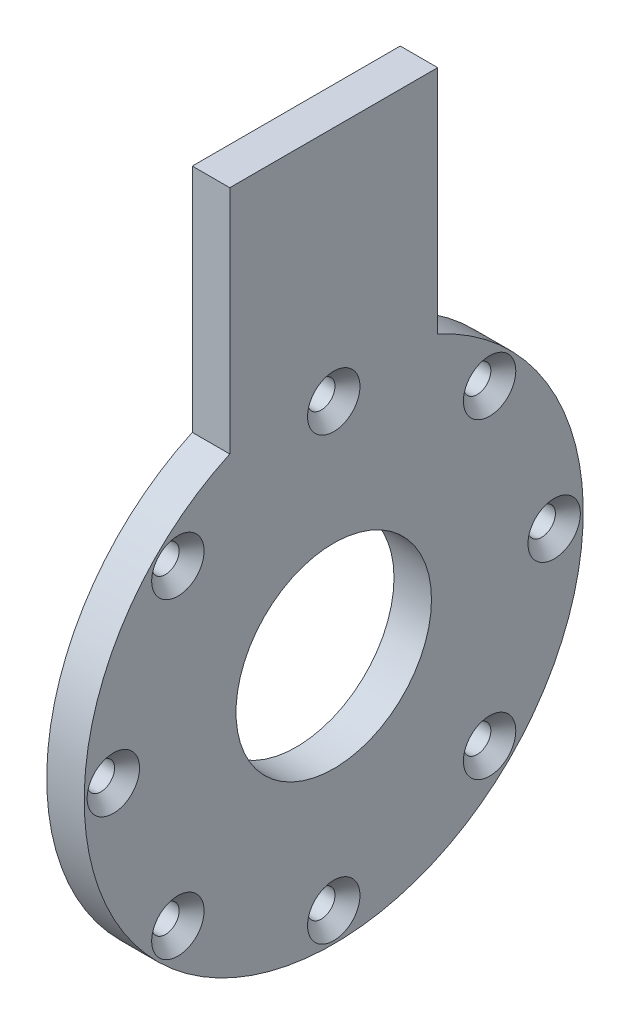
from build123d import *

# Parameters (mm, degrees)
SKETCH1_R                                           = 23.5
BOSS_EXTRUDE1_DEPTH                                 = 9
BOSS_EXTRUDE1_DEPTH_BACK                            = 0.01
CSK_FOR_M6_COUNTERSUNK_FLAT_HEAD_SCREW1_D           = 6.6
CSK_FOR_M6_COUNTERSUNK_FLAT_HEAD_SCREW1_CSINK_D     = 12.6
CSK_FOR_M6_COUNTERSUNK_FLAT_HEAD_SCREW1_CSINK_ANGLE = 90


with BuildPart() as part:
    # Sketch1 → Boss-Extrude1 (new body, two sides)
    with BuildSketch(Plane(origin=(0, 0, 0), x_dir=(0, 0, -1), z_dir=(1, 0, 0))) as boss_extrude1_sk:
        with BuildLine():
            Line((-25, 110), (25, 110))
            Line((25, 110), (25, 54.543560573))
            ThreePointArc((25, 54.543560573), (0, -60), (-25, 54.543560573))
            Line((-25, 54.543560573), (-25, 110))
        make_face()
        Circle(SKETCH1_R, mode=Mode.SUBTRACT)
    extrude(amount=BOSS_EXTRUDE1_DEPTH)
    extrude(boss_extrude1_sk.sketch, amount=-BOSS_EXTRUDE1_DEPTH_BACK)

    # CSK for M6 Countersunk Flat Head Screw1 (through all)
    with Locations(Plane(origin=(9, 0, 0), x_dir=(0, 0, -1), z_dir=(1, 0, 0))):
        with Locations((-37.476659403, 37.476659403), (0, 53), (37.476659403, 37.476659403), (53, 0), (37.476659403, -37.476659403), (0, -53), (-37.476659403, -37.476659403), (-53, 0)):
            CounterSinkHole(CSK_FOR_M6_COUNTERSUNK_FLAT_HEAD_SCREW1_D / 2, CSK_FOR_M6_COUNTERSUNK_FLAT_HEAD_SCREW1_CSINK_D / 2, counter_sink_angle=CSK_FOR_M6_COUNTERSUNK_FLAT_HEAD_SCREW1_CSINK_ANGLE)


solid = part.part
